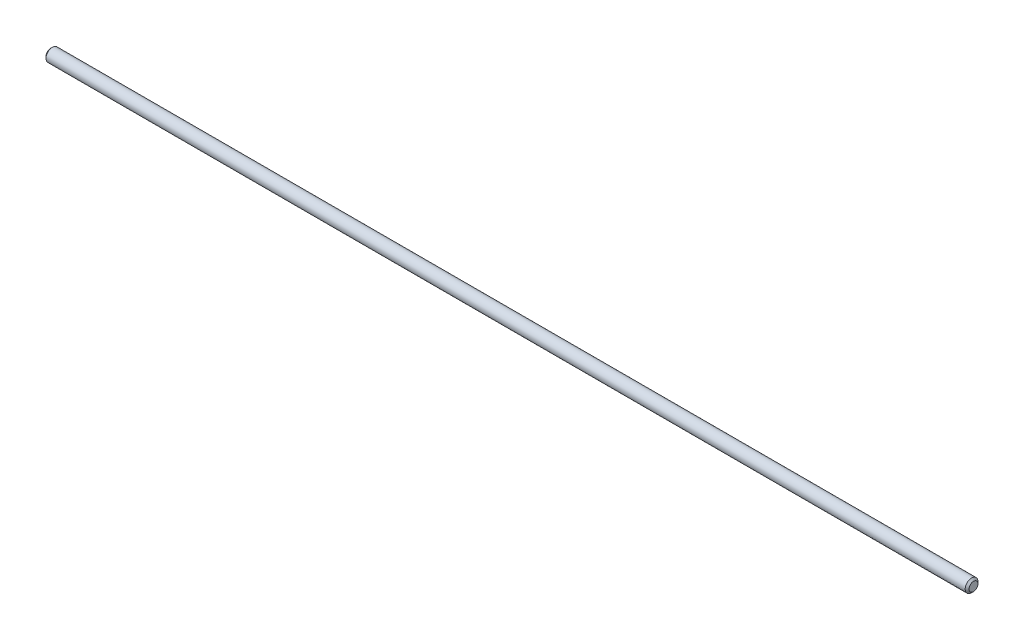
from build123d import *

# Parameters (mm, degrees)
SKETCH2_R                = 3.175
BOSS_EXTRUDE1_DEPTH      = 228.6
BOSS_EXTRUDE1_DEPTH_BACK = 228.6
CHAMFER1_SIZE            = 0.9525


with BuildPart() as part:
    # Sketch2 → Boss-Extrude1 (new body, two sides)
    with BuildSketch(Plane(origin=(0, 0, 0), x_dir=(0, 0, -1), z_dir=(1, 0, 0))) as boss_extrude1_sk:
        Circle(SKETCH2_R)
    extrude(amount=BOSS_EXTRUDE1_DEPTH)
    extrude(boss_extrude1_sk.sketch, amount=-BOSS_EXTRUDE1_DEPTH_BACK)

    # Chamfer1
    chamfer1_edges = [part.edges().sort_by_distance(p)[0] for p in [
        (-228.6, 0, 3.175),
        (228.6, 0, 3.175),
    ]]
    chamfer(chamfer1_edges, length=CHAMFER1_SIZE)


solid = part.part
